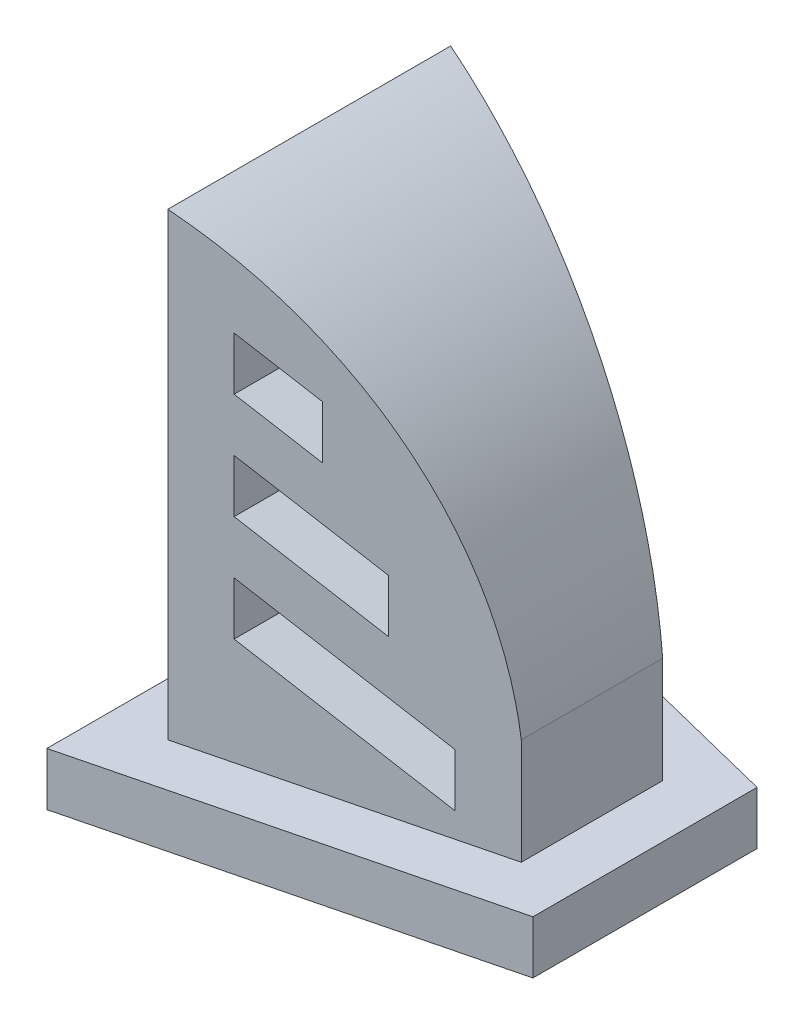
from build123d import *

# Parameters (mm, degrees)
EXTRUDE1_DEPTH = 15
EXTRUDE2_DEPTH = 130
EXTRUDE3_DEPTH = 65


with BuildPart() as part:
    # Sketch1 → Extrude1 (new body)
    with BuildSketch(Plane(origin=(0, 0, 0), x_dir=(1, 0, 0), z_dir=(0, 1, 0))):
        Polygon((15, -11.711646096), (-95, -39.211646096), (-95, 79.211646096), (15, 51.711646096), align=None)
    extrude(amount=EXTRUDE1_DEPTH)

    # Sketch2 → Extrude2 (add)
    with BuildSketch(Plane(origin=(0, 15, 0), x_dir=(1, 0, 0), z_dir=(0, 1, 0))):
        Polygon((0, 0), (0, 40), (-80, 60), (-80, -20), align=None)
    extrude(amount=EXTRUDE2_DEPTH)

    # Sketch3 → Extrude3 (cut, symmetric)
    with BuildSketch(Plane.XY):
        with BuildLine():
            Line((-80, 145), (0, 145))
            Line((0, 145), (0, 45))
            ThreePointArc((0, 45), (-25.545271603, 106.563782718), (-80, 145))
        make_face()
        Polygon((-65, 120.30999778), (-65, 105.30999778), (-45, 95.983844617), (-45, 110.983844617), align=None)
        Polygon((-65, 45.30999778), (-15, 21.994614872), (-15, 36.994614872), (-65, 60.30999778), align=None)
        Polygon((-65, 75.30999778), (-30, 58.989229745), (-30, 73.989229745), (-65, 90.30999778), align=None)
    extrude(amount=EXTRUDE3_DEPTH, both=True, mode=Mode.SUBTRACT)


solid = part.part
